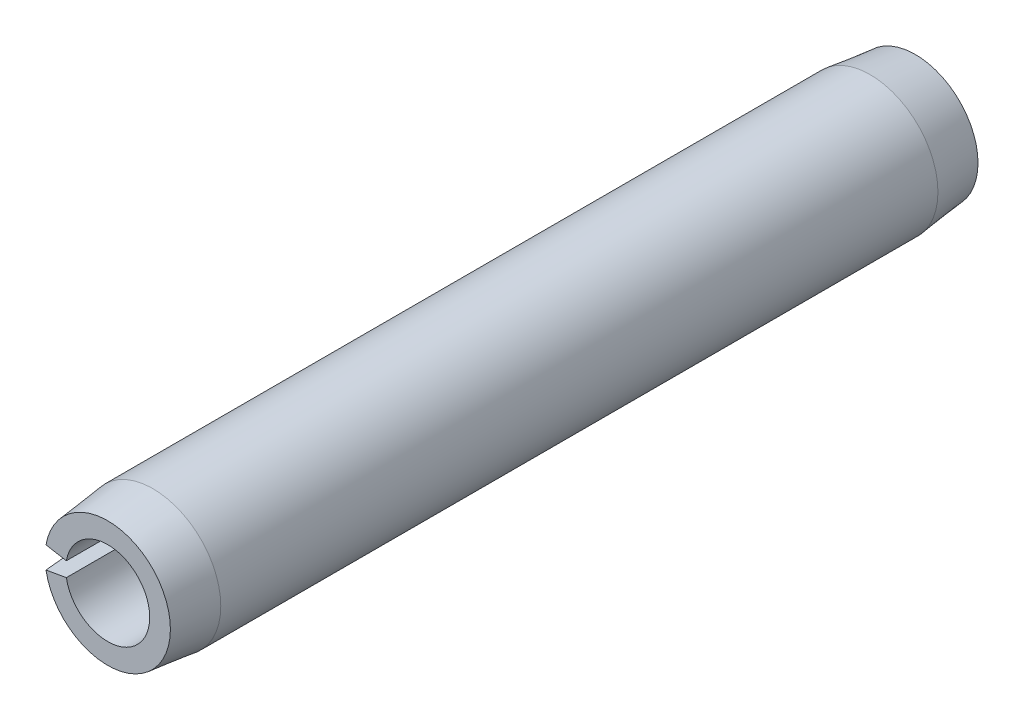
from build123d import *

# Parameters (mm, degrees)
EXTRUDE1_DEPTH      = 4.7625
EXTRUDE1_DEPTH_BACK = 4.7625


with BuildPart() as part:
    # Sketch1 → Extrude1 (new body, two sides)
    with BuildSketch(Plane.XY) as extrude1_sk:
        with BuildLine():
            Line((-0.48777528, -0.086007942), (-0.787944683, -0.138935907))
            ThreePointArc((-0.787944683, -0.138935907), (0.8001, 0), (-0.787944683, 0.138935907))
            Line((-0.787944683, 0.138935907), (-0.48777528, 0.086007942))
            ThreePointArc((-0.48777528, 0.086007942), (0.4953, 0), (-0.48777528, -0.086007942))
        make_face()
    extrude(amount=EXTRUDE1_DEPTH)
    extrude(extrude1_sk.sketch, amount=-EXTRUDE1_DEPTH_BACK)

    # Sketch2 → Cut-Revolve1 (revolve, cut)
    with BuildSketch(Plane(origin=(0, 0, 0), x_dir=(0, 0, -1), z_dir=(1, 0, 0))):
        Polygon((4.7625, 0.73914), (4.2291, 0.8001), (4.7625, 0.8001), align=None)
    cut_revolve1 = revolve(axis=Axis((0, 0, -4.7625), (0, 0, 1)), mode=Mode.SUBTRACT)

    # Mirror1: Cut-Revolve1 across plane
    add(cut_revolve1.mirror(Plane.XY), mode=Mode.SUBTRACT)


solid = part.part
